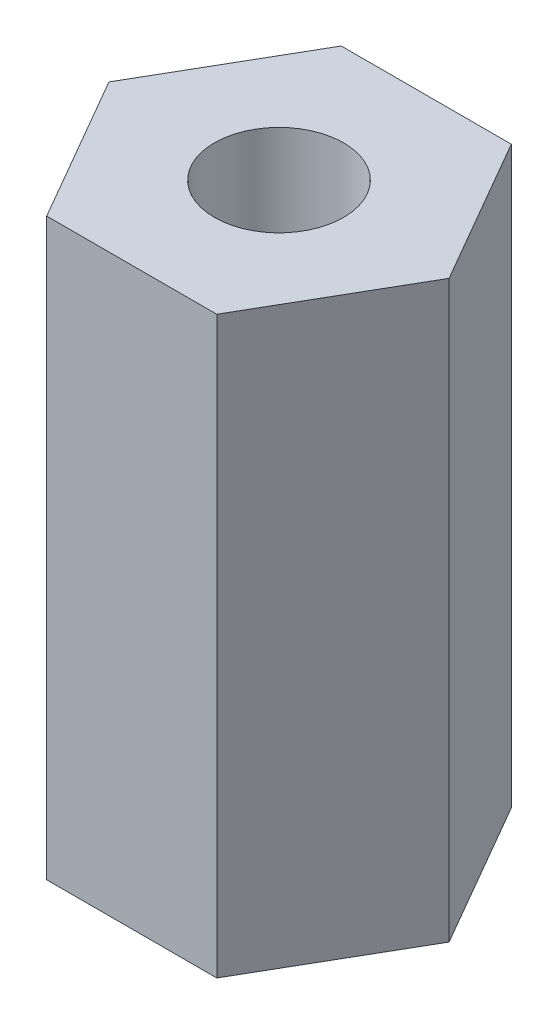
from build123d import *

# Parameters (mm, degrees)
BOSS_EXTRUDE1_DEPTH = 16.9
SKETCH3_R           = 1.9
CUT_EXTRUDE1_DEPTH  = 17.9


with BuildPart() as part:
    # Sketch1 → Boss-Extrude1 (new body)
    with BuildSketch(Plane(origin=(0, 0, 0), x_dir=(1, 0, 0), z_dir=(0, 1, 0))):
        Polygon((5, 0), (2.5, 4.330127019), (-2.5, 4.330127019), (-5, 0), (-2.5, -4.330127019), (2.5, -4.330127019), align=None)
    extrude(amount=BOSS_EXTRUDE1_DEPTH)

    # Sketch3 → Cut-Extrude1 (cut, through all)
    with BuildSketch(Plane(origin=(0, 16.9, 0), x_dir=(1, 0, 0), z_dir=(0, 1, 0))):
        Circle(SKETCH3_R)
    extrude(amount=-CUT_EXTRUDE1_DEPTH, mode=Mode.SUBTRACT)


solid = part.part
